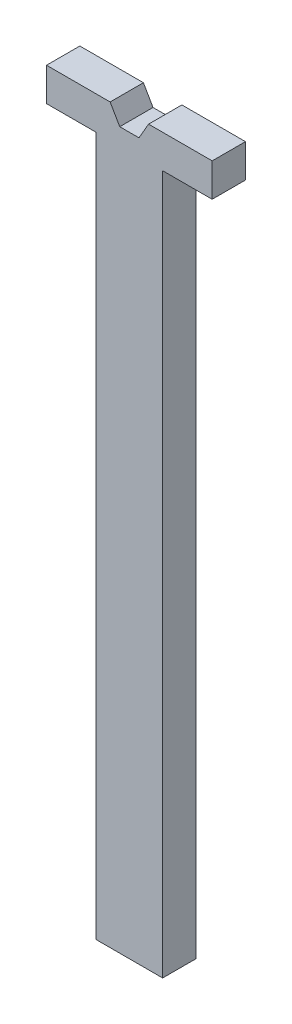
from build123d import *

# Parameters (mm, degrees)
SKETCH1_W           = 20
SKETCH1_H           = 200
SKETCH1_H_2         = 10
SKETCH1_W_2         = 14.875
BOSS_EXTRUDE1_DEPTH = 10


with BuildPart() as part:
    # Sketch1 → Boss-Extrude1 (new body)
    with BuildSketch(Plane.XY):
        with Locations((0, -115)):
            Rectangle(SKETCH1_W, SKETCH1_H)
        with Locations((0, -10)):
            Rectangle(SKETCH1_W, SKETCH1_H_2)
        Polygon((-10, 5), (-10, -5), (10, -5), (10, 5), (5.773502692, 5), (2.886751346, 0), (-2.886751346, 0), (-5.773502692, 5), align=None)
        with Locations((-17.4375, 0)):
            Rectangle(SKETCH1_W_2, SKETCH1_H_2)
        with Locations((17.4375, 0)):
            Rectangle(SKETCH1_W_2, SKETCH1_H_2)
    extrude(amount=BOSS_EXTRUDE1_DEPTH)


solid = part.part
